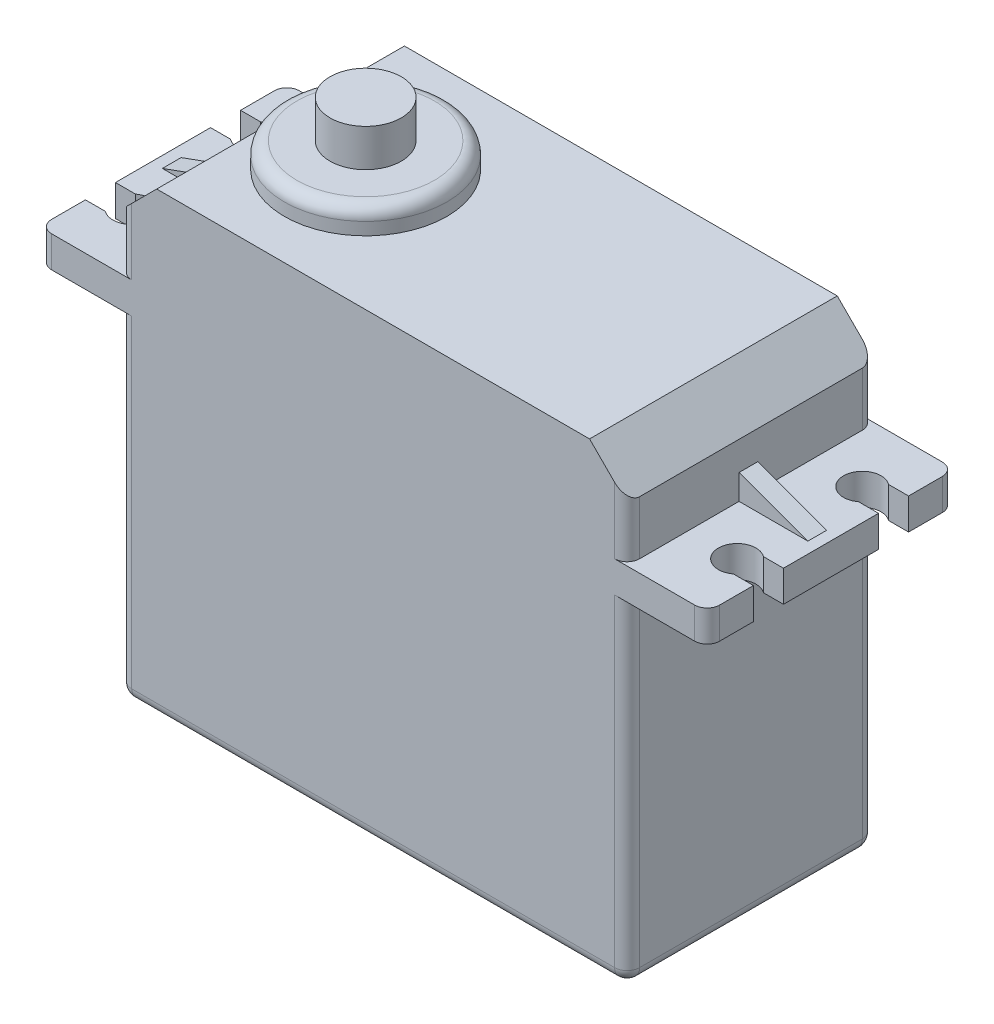
from build123d import *

# Parameters (mm, degrees)
MAIN_SERVO_BODY_DEPTH       = 19.8
SERVO_BRACKET_DEPTH         = 30.3
SKETCH3_R                   = 6.5
SERVO_AXIS_1_DEPTH          = 2
SERVO_BRACKET_SUPPORT_DEPTH = 0.75
SKETCH5_R                   = 2.85
SERVO_AXIS_2_DEPTH          = 3
SKETCH6_R                   = 2.5
SERVO_WIRES_DEPTH           = 2
SERVO_CONTOURING_R          = 1


with BuildPart() as part:
    # Sketch1 → Main Servo Body (new body)
    with BuildSketch(Plane.XY):
        Polygon((0, 0), (40.6, 0), (40.6, 26.8), (47, 26.8), (47, 29.3), (40.6, 29.3), (40.6, 33.6), (37.6, 36.6), (3, 36.6), (0, 33.6), (0, 29.3), (-6.4, 29.3), (-6.4, 26.8), (0, 26.8), align=None)
    extrude(amount=MAIN_SERVO_BODY_DEPTH)

    # Sketch2 → Servo Bracket (cut, through all)
    with BuildSketch(Plane(origin=(0, 29.3, 0), x_dir=(1, 0, 0), z_dir=(0, 1, 0))):
        with BuildLine():
            Line((-6.4, -3.7), (-4.8, -3.7))
            ThreePointArc((-4.8, -3.7), (-2.4, -4.9), (-4.8, -6.1))
            Line((-4.8, -6.1), (-6.4, -6.1))
            Line((-6.4, -6.1), (-6.4, -3.7))
        make_face()
        with BuildLine():
            Line((45.4, -3.7), (47, -3.7))
            Line((47, -3.7), (47, -6.1))
            Line((47, -6.1), (45.4, -6.1))
            ThreePointArc((45.4, -6.1), (43, -4.9), (45.4, -3.7))
        make_face()
        with BuildLine():
            Line((45.4, -13.7), (47, -13.7))
            Line((47, -13.7), (47, -16.1))
            Line((47, -16.1), (45.4, -16.1))
            ThreePointArc((45.4, -16.1), (43, -14.9), (45.4, -13.7))
        make_face()
        with BuildLine():
            Line((-6.4, -16.1), (-6.4, -13.7))
            Line((-6.4, -13.7), (-4.8, -13.7))
            ThreePointArc((-4.8, -13.7), (-2.4, -14.9), (-4.8, -16.1))
            Line((-4.8, -16.1), (-6.4, -16.1))
        make_face()
    extrude(amount=-SERVO_BRACKET_DEPTH, mode=Mode.SUBTRACT)

    # Sketch3 → Servo Axis 1 (add)
    with BuildSketch(Plane(origin=(0, 36.6, 0), x_dir=(1, 0, 0), z_dir=(0, 1, 0))):
        with Locations((10, -10.1)):
            Circle(SKETCH3_R)
    extrude(amount=SERVO_AXIS_1_DEPTH)

    # Sketch4 → Servo Bracket Support (add, symmetric)
    with BuildSketch(Plane.XY.offset(10.1)):
        Polygon((-5.5, 29.3), (0, 31.3), (0, 29.3), align=None)
        Polygon((40.6, 29.3), (46.1, 29.3), (40.6, 31.3), align=None)
    extrude(amount=SERVO_BRACKET_SUPPORT_DEPTH, both=True)

    # Sketch5 → Servo Axis 2 (add)
    with BuildSketch(Plane(origin=(0, 38.6, 0), x_dir=(1, 0, 0), z_dir=(0, 1, 0))):
        with Locations((10, -10.1)):
            Circle(SKETCH5_R)
    extrude(amount=SERVO_AXIS_2_DEPTH)

    # Sketch6 → Servo Wires (add)
    with BuildSketch(Plane.ZY):
        with Locations((10.1, 6)):
            Circle(SKETCH6_R)
    extrude(amount=SERVO_WIRES_DEPTH)

    # Servo Contouring
    servo_contouring_edges = [part.edges().sort_by_distance(p)[0] for p in [
        (40.6, 13.4, 19.8),
        (3.5, 38.6, 10.1),
        (-6.4, 28.05, 0),
        (0, 31.45, 0),
        (40.6, 31.45, 0),
        (47, 28.05, 19.8),
        (47, 28.05, 0),
        (40.6, 13.4, 0),
        (20.3, 0, 0),
        (0, 13.4, 0),
        (40.6, 31.45, 19.8),
        (40.6, 0, 9.9),
        (0, 0, 9.9),
        (0, 31.45, 19.8),
        (0, 13.4, 19.8),
        (-6.4, 28.05, 19.8),
        (20.3, 0, 19.8),
    ]]
    fillet(servo_contouring_edges, radius=SERVO_CONTOURING_R)


solid = part.part
